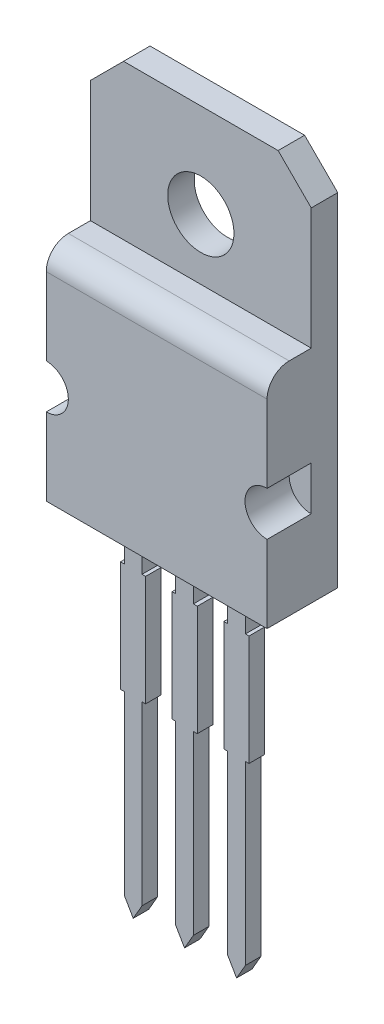
from build123d import *

# Parameters (mm, degrees)
BOSS_EXTRUDE1_DEPTH   = 17.78
BOSS_EXTRUDE1_2_DEPTH = 17.78
BOSS_EXTRUDE1_3_DEPTH = 17.78
SKETCH2_W             = 254
SKETCH2_H             = 254
BOSS_EXTRUDE2_DEPTH   = 50.8
FILLET1_R             = 25.4
SKETCH3_R             = 25.4
CUT_EXTRUDE1_DEPTH    = 50.8
BOSS_EXTRUDE3_DEPTH   = 30.48
SKETCH5_R             = 38.1
CUT_EXTRUDE2_DEPTH    = 30.48


with BuildPart() as part:
    # Sketch1 → Boss-Extrude1 (new body)
    with BuildSketch(Plane.XY):
        Polygon((0, 0), (20.32, 0), (20.32, -50.8), (24.432509982, -50.8), (24.432509982, -177.8), (20.32, -177.8), (20.32, -381), (10.16, -398.597636205), (0, -381), (0, -177.8), (-4.523490018, -177.8), (-4.523490018, -50.8), (0, -50.8), align=None)
    extrude(amount=BOSS_EXTRUDE1_DEPTH)



with BuildPart() as body_2:
    # Sketch1 → Boss-Extrude1 2 (new body)
    with BuildSketch(Plane.XY):
        Polygon((-59.846980035, -50.8), (-59.846980035, 0), (-39.526980035, 0), (-39.526980035, -50.8), (-35.003490018, -50.8), (-35.003490018, -177.8), (-39.526980035, -177.8), (-39.526980035, -381), (-49.686980035, -398.597636205), (-59.846980035, -381), (-59.846980035, -177.8), (-63.959490018, -177.8), (-63.959490018, -50.8), align=None)
    extrude(amount=BOSS_EXTRUDE1_2_DEPTH)


with BuildPart() as body_3:
    # Sketch1 → Boss-Extrude1 3 (new body)
    with BuildSketch(Plane.XY):
        Polygon((-118.872, -381), (-108.712, -398.597636205), (-98.552, -381), (-98.552, -177.8), (-94.439490018, -177.8), (-94.439490018, -50.8), (-98.552, -50.8), (-98.552, 0), (-118.872, 0), (-118.872, -50.8), (-123.395490018, -50.8), (-123.395490018, -177.8), (-118.872, -177.8), align=None)
    extrude(amount=BOSS_EXTRUDE1_3_DEPTH)


with BuildPart() as part_1:
    add(part.part)

    add(body_2.part)  # Boss-Extrude2 merges body 2

    add(body_3.part)  # Boss-Extrude2 merges body 3
    # Sketch2 → Boss-Extrude2 (add)
    with BuildSketch(Plane.XY):
        with Locations((-48.724161458, 127)):
            Rectangle(SKETCH2_W, SKETCH2_H)
    extrude(amount=BOSS_EXTRUDE2_DEPTH)

    # Fillet1
    fillet1_edges = [part_1.edges().sort_by_distance(p)[0] for p in [
        (-48.724161458, 254, 50.8),
    ]]
    fillet(fillet1_edges, radius=FILLET1_R)

    # Sketch3 → Cut-Extrude1 (cut)
    with BuildSketch(Plane.XY.offset(50.8)):
        with Locations((-175.724161458, 114.3)):
            Circle(SKETCH3_R)
        with Locations((78.275838542, 114.3)):
            Circle(SKETCH3_R)
    extrude(amount=-CUT_EXTRUDE1_DEPTH, mode=Mode.SUBTRACT)

    # Sketch4 → Boss-Extrude3 (add)
    with BuildSketch(Plane(origin=(0, 0, 0), x_dir=(-1, 0, 0), z_dir=(0, 0, -1))):
        Polygon((-78.275838542, 393.7), (-40.175838542, 431.8), (137.624161458, 431.8), (175.724161458, 393.7), (175.724161458, 0), (-78.275838542, 0), align=None)
    extrude(amount=BOSS_EXTRUDE3_DEPTH)

    # Sketch5 → Cut-Extrude2 (cut)
    with BuildSketch(Plane.XY):
        with Locations((-48.724161458, 323.85)):
            Circle(SKETCH5_R)
    extrude(amount=-CUT_EXTRUDE2_DEPTH, mode=Mode.SUBTRACT)


solid = part_1.part
